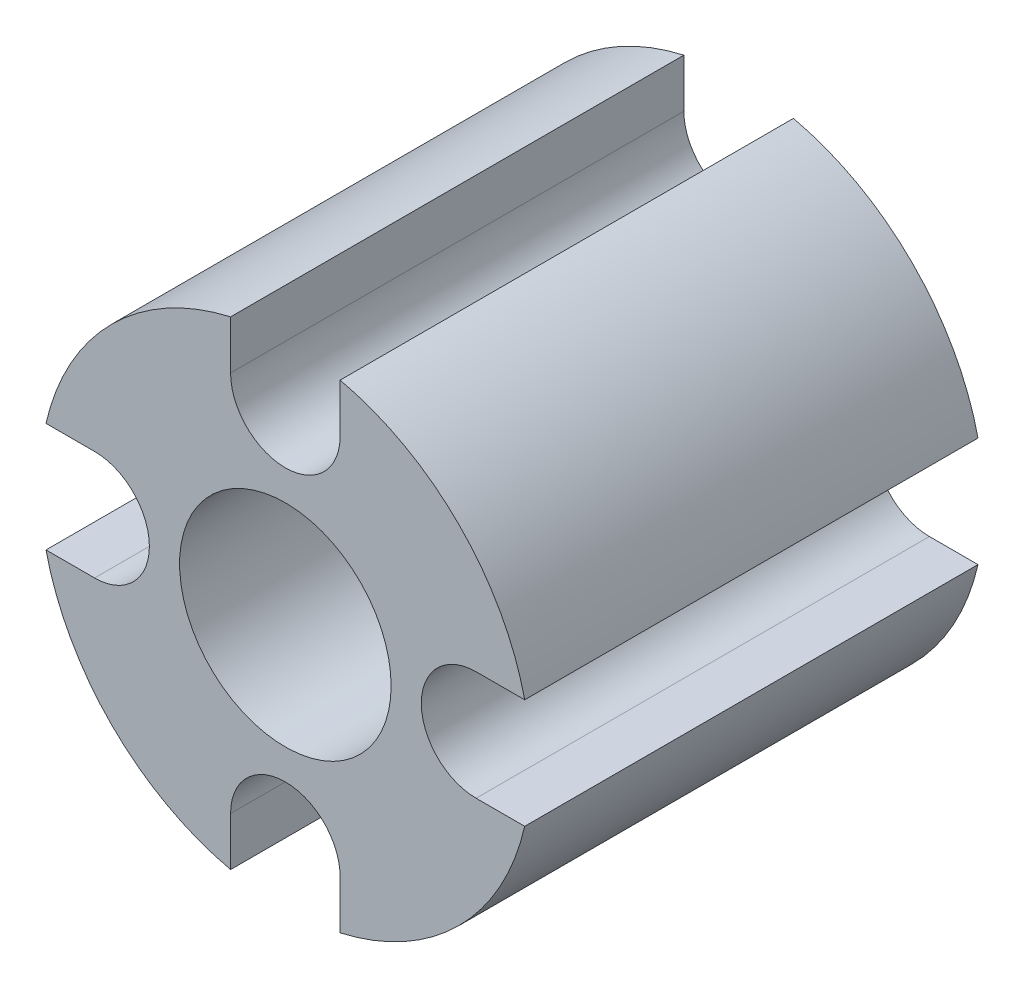
from build123d import *

# Parameters (mm, degrees)
ESQUISSE1_R        = 1.4
BOSS_EXTRU_2_DEPTH = 6


with BuildPart() as part:
    # Esquisse1 → Boss.-Extru.2 (new body)
    with BuildSketch(Plane.XY):
        with BuildLine():
            Line((-0.725, 2.525), (-0.725, 3.168102745))
            ThreePointArc((-0.725, 3.168102745), (-2.298097039, 2.298097039), (-3.168102745, 0.725))
            Line((-3.168102745, 0.725), (-2.525, 0.725))
            ThreePointArc((-2.525, 0.725), (-1.8, 0), (-2.525, -0.725))
            Line((-2.525, -0.725), (-3.168102745, -0.725))
            ThreePointArc((-3.168102745, -0.725), (-2.298097039, -2.298097039), (-0.725, -3.168102745))
            Line((-0.725, -3.168102745), (-0.725, -2.525))
            ThreePointArc((-0.725, -2.525), (0, -1.8), (0.725, -2.525))
            Line((0.725, -2.525), (0.725, -3.168102745))
            ThreePointArc((0.725, -3.168102745), (2.298097039, -2.298097039), (3.168102745, -0.725))
            Line((3.168102745, -0.725), (2.525, -0.725))
            ThreePointArc((2.525, -0.725), (1.8, 0), (2.525, 0.725))
            Line((2.525, 0.725), (3.168102745, 0.725))
            ThreePointArc((3.168102745, 0.725), (2.298097039, 2.298097039), (0.725, 3.168102745))
            Line((0.725, 3.168102745), (0.725, 2.525))
            ThreePointArc((0.725, 2.525), (0, 1.8), (-0.725, 2.525))
        make_face()
        Circle(ESQUISSE1_R, mode=Mode.SUBTRACT)
    extrude(amount=BOSS_EXTRU_2_DEPTH)


solid = part.part
